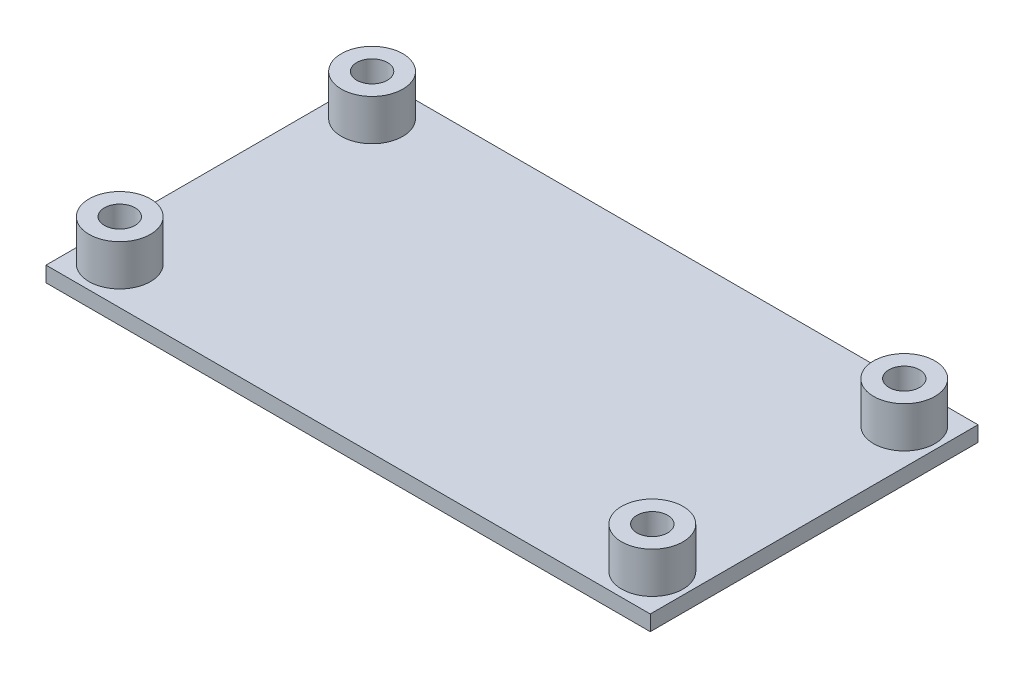
from build123d import *

# Parameters (mm, degrees)
SKETCH_2_W          = 57
SKETCH_2_H          = 40.4
EXTRUDE_1_DEPTH     = 1.5
SKETCH_4_R          = 3
SKETCH_4_R_2        = 1.5
EXTRUDE_3_DEPTH     = 4
SKETCH_5_W          = 57
SKETCH_5_H          = 4.2
CUT_EXTRUDE_1_DEPTH = 2.5
SKETCH_6_W          = 1
SKETCH_6_H          = 32
EXTRUDE_4_DEPTH     = 1.5


with BuildPart() as part:
    # 草图2 → 凸台-拉伸1 (new body)
    with BuildSketch(Plane(origin=(0, 0, 0), x_dir=(1, 0, 0), z_dir=(0, 1, 0))):
        with Locations((3.861898857, -4.534326193)):
            Rectangle(SKETCH_2_W, SKETCH_2_H)
    extrude(amount=EXTRUDE_1_DEPTH)

    # 草图4 → 凸台-拉伸3 (add)
    with BuildSketch(Plane(origin=(0, 1.5, 0), x_dir=(1, 0, 0), z_dir=(0, 1, 0))):
        with Locations((-22.099370277, 7.765673807)):
            Circle(SKETCH_4_R)
        with Locations((-22.099370277, 7.765673807)):
            Circle(SKETCH_4_R_2, mode=Mode.SUBTRACT)
        with Locations((-22.138101143, -16.834326193)):
            Circle(SKETCH_4_R)
        with Locations((-22.138101143, -16.834326193)):
            Circle(SKETCH_4_R_2, mode=Mode.SUBTRACT)
        with Locations((29.861898857, -16.834326193)):
            Circle(SKETCH_4_R)
        with Locations((29.861898857, -16.834326193)):
            Circle(SKETCH_4_R_2, mode=Mode.SUBTRACT)
        with Locations((29.861898857, 7.765673807)):
            Circle(SKETCH_4_R)
        with Locations((29.861898857, 7.765673807)):
            Circle(SKETCH_4_R_2, mode=Mode.SUBTRACT)
    extrude(amount=EXTRUDE_3_DEPTH)

    # 草图5 → 切除-拉伸1 (cut, through all)
    with BuildSketch(Plane(origin=(0, 1.5, 0), x_dir=(1, 0, 0), z_dir=(0, 1, 0))):
        with Locations((3.861898857, 13.565673807)):
            Rectangle(SKETCH_5_W, SKETCH_5_H)
        with Locations((3.861898857, -22.634326193)):
            Rectangle(SKETCH_5_W, SKETCH_5_H)
    extrude(amount=-CUT_EXTRUDE_1_DEPTH, mode=Mode.SUBTRACT)

    # 草图6 → 凸台-拉伸4 (add)
    with BuildSketch(Plane(origin=(0, 1.5, 0), x_dir=(1, 0, 0), z_dir=(0, 1, 0))):
        with Locations((-25.138101143, -4.534326193)):
            Rectangle(SKETCH_6_W, SKETCH_6_H)
        with Locations((32.861898857, -4.534326193)):
            Rectangle(SKETCH_6_W, SKETCH_6_H)
    extrude(amount=-EXTRUDE_4_DEPTH)


solid = part.part
